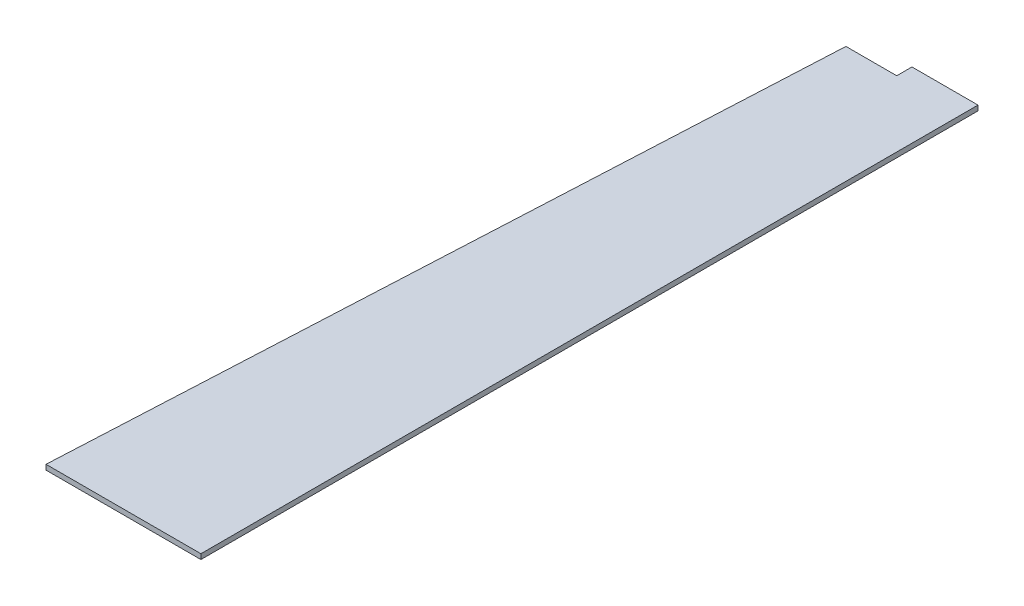
from build123d import *

# Parameters (mm, degrees)
EXTRUSION1_DEPTH = 10


with BuildPart() as part:
    # Esquisse1 → Extrusion1 (new body)
    with BuildSketch(Plane(origin=(0, 0, 0), x_dir=(1, 0, 0), z_dir=(0, 1, 0))):
        Polygon((325, 0), (400, 1500), (500, 1500), (500, 1530), (630, 1530), (630, 0), align=None)
    extrude(amount=EXTRUSION1_DEPTH)


solid = part.part
